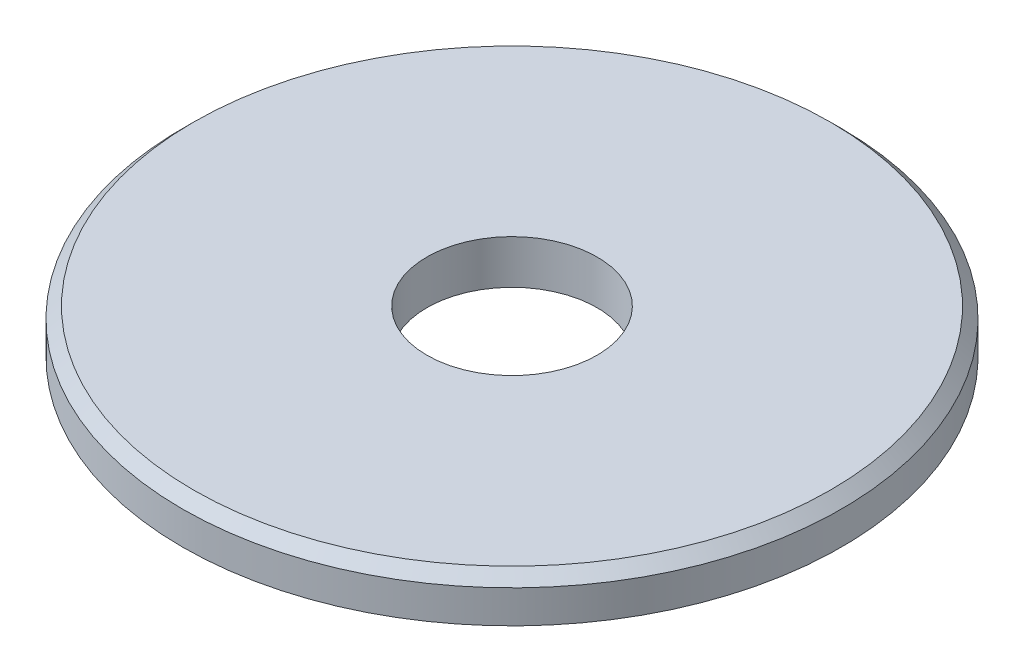
from build123d import *

# Parameters (mm, degrees)
SKETCH_1_R      = 6
SKETCH_1_R_2    = 1.55
EXTRUDE_1_DEPTH = 0.8
CHAMFER_1_SIZE  = 0.2


with BuildPart() as part:
    # 草图1 → 凸台-拉伸1 (new body)
    with BuildSketch(Plane(origin=(0, 0, 0), x_dir=(1, 0, 0), z_dir=(0, 1, 0))):
        Circle(SKETCH_1_R)
        Circle(SKETCH_1_R_2, mode=Mode.SUBTRACT)
    extrude(amount=EXTRUDE_1_DEPTH)

    # 倒角1
    chamfer_1_edges = [part.edges().sort_by_distance(p)[0] for p in [
        (-6, 0.8, 0),
    ]]
    chamfer(chamfer_1_edges, length=CHAMFER_1_SIZE)


solid = part.part
